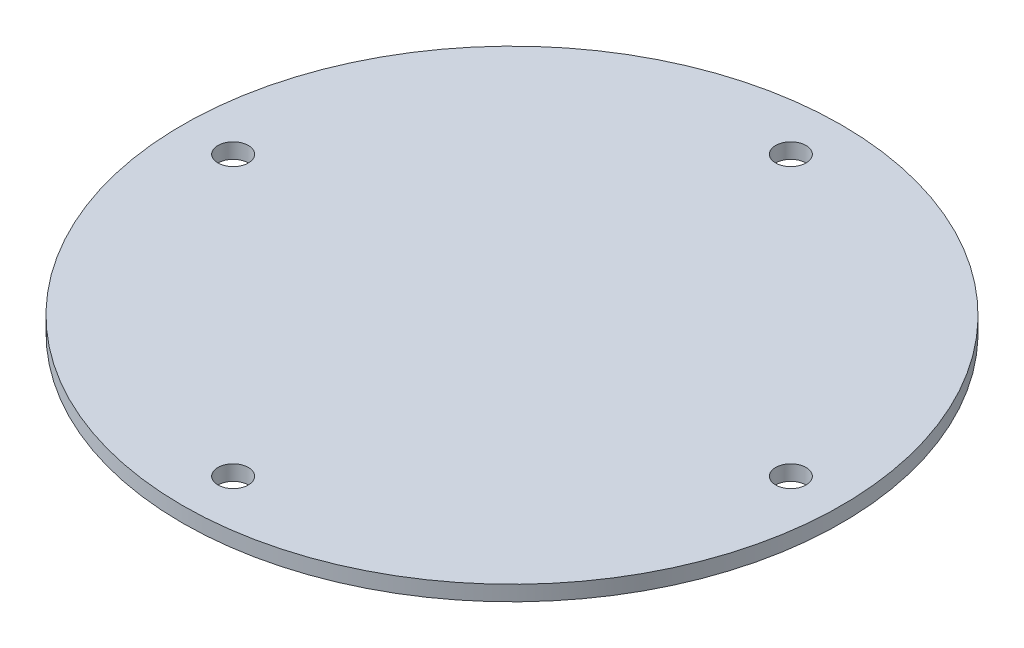
from build123d import *

# Parameters (mm, degrees)
SKETCH1_R           = 65
BOSS_EXTRUDE1_DEPTH = 3
SKETCH2_R           = 3
CUT_EXTRUDE1_DEPTH  = 4
CIRPATTERN1_COUNT   = 4


with BuildPart() as part:
    # Sketch1 → Boss-Extrude1 (new body)
    with BuildSketch(Plane(origin=(0, 0, 0), x_dir=(1, 0, 0), z_dir=(0, 1, 0))):
        Circle(SKETCH1_R)
    extrude(amount=BOSS_EXTRUDE1_DEPTH)

    # Sketch2 → Cut-Extrude1 (cut, through all)
    with BuildSketch(Plane(origin=(0, 3, 0), x_dir=(1, 0, 0), z_dir=(0, 1, 0))):
        with Locations((0, 55)):
            Circle(SKETCH2_R)
    cut_extrude1 = extrude(amount=-CUT_EXTRUDE1_DEPTH, mode=Mode.SUBTRACT)

    # CirPattern1: Cut-Extrude1 ×4 about axis
    cirpattern1_axis = Axis((0, 0, 0), (0, 1, 0))
    for i in range(1, CIRPATTERN1_COUNT):
        add(cut_extrude1.rotate(cirpattern1_axis, i * 360 / CIRPATTERN1_COUNT), mode=Mode.SUBTRACT)


solid = part.part
